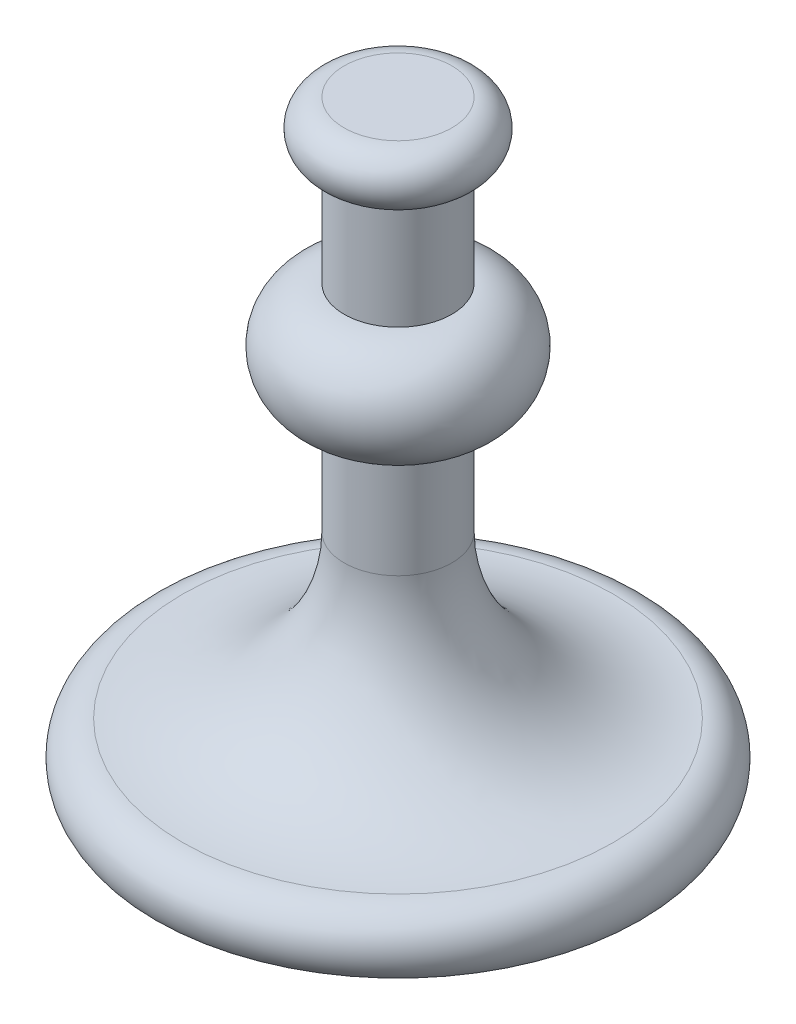
from build123d import *


with BuildPart() as part:
    # Sketch1 → Revolve1 (revolve)
    with BuildSketch(Plane.XY):
        with BuildLine():
            Line((0, 0), (0, 220))
            Line((0, 220), (20, 220))
            ThreePointArc((20, 220), (30, 210), (20, 200))
            Line((20, 200), (20, 160))
            ThreePointArc((20, 160), (40, 140), (20, 120))
            Line((20, 120), (20, 80.001263784))
            ThreePointArc((20, 80.001263784), (37.573593129, 37.574856913), (80, 20.001263784))
            ThreePointArc((80, 20.001263784), (91.180905073, 13.090889158), (90, 0))
            Line((90, 0), (0, 0))
        make_face()
    revolve(axis=Axis((0, 220, 0), (0, 1, 0)))


solid = part.part
